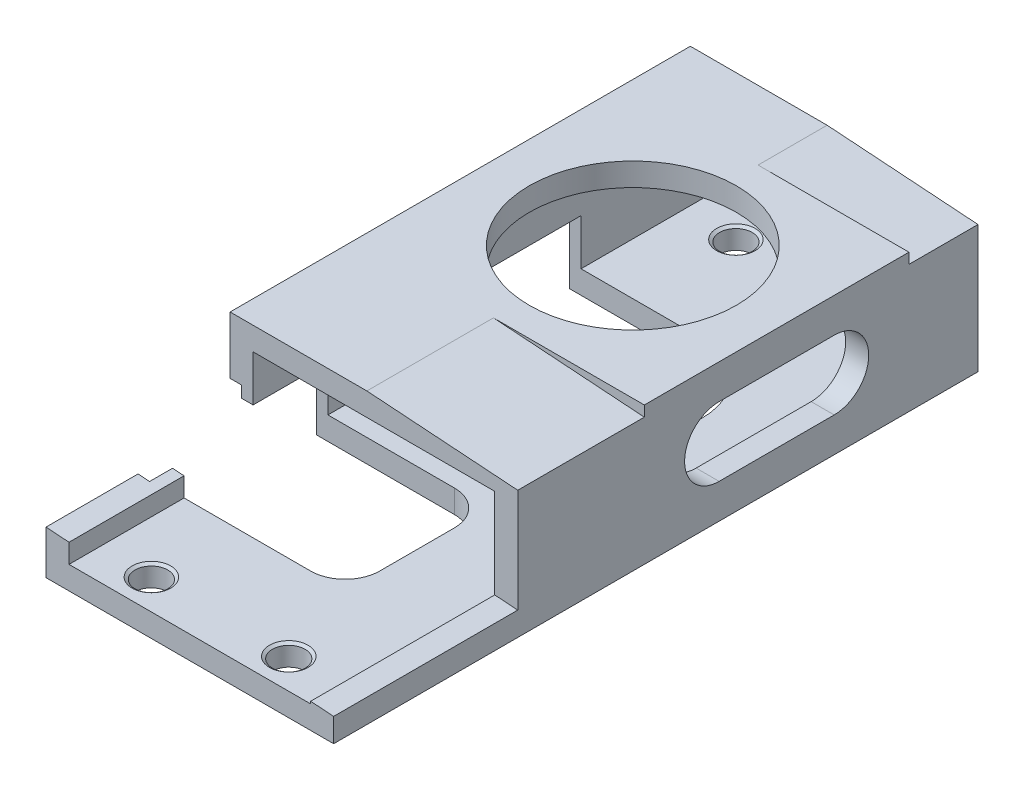
from build123d import *

# Parameters (mm, degrees)
SKETCH_1_W                   = 25
SKETCH_1_H                   = 12
SKETCH_1_W_2                 = 21
SKETCH_1_H_2                 = 8
EXTRUDE_1_DEPTH              = 56
CUT_EXTRUDE_1_REACH          = 14
SKETCH_2_R                   = 9
HOLE_WIZARD_4_401_AT_2_COUNT = 2
HOLE_WIZARD_4_401_AT_2_PITCH = 50.8
HOLE_WIZARD_4_401_AT_3_COUNT = 2
HOLE_WIZARD_4_401_AT_3_PITCH = 52.184323316
HOLE_WIZARD_4_401_AT_4_COUNT = 2
HOLE_WIZARD_4_401_AT_4_PITCH = 11.94
CUT_EXTRUDE_2_DEPTH          = 6
CUT_EXTRUDE_4_DEPTH          = 1
CUT_EXTRUDE_8_REACH          = 27
CUT_EXTRUDE_9_DEPTH          = 6
CUT_EXTRUDE_START            = -56
CUT_EXTRUDE_10_DEPTH         = 27
SKETCH_15_W                  = 30.69445118
SKETCH_15_H                  = 18.97035636
CUT_EXTRUDE_11_DEPTH         = 9


with BuildPart() as part:
    # Sketch 1 → Extrude 1 (new body)
    with BuildSketch(Plane.XY):
        Rectangle(SKETCH_1_W, SKETCH_1_H)
        Rectangle(SKETCH_1_W_2, SKETCH_1_H_2, mode=Mode.SUBTRACT)
    extrude(amount=EXTRUDE_1_DEPTH)

    # Sketch 2 → Cut-Extrude 1 (cut, up to next)
    with BuildSketch(Plane(origin=(0, 6, 0), x_dir=(1, 0, 0), z_dir=(0, 1, 0)), mode=Mode.PRIVATE) as cut_extrude_1_sk1:
        with Locations((0, -17.5)):
            Circle(SKETCH_2_R)
    cut_extrude_1_tool1 = extrude(cut_extrude_1_sk1.sketch, amount=-CUT_EXTRUDE_1_REACH, mode=Mode.PRIVATE) & part.part
    add(cut_extrude_1_tool1.solids().sort_by_distance((0, 6, 17.5))[0], mode=Mode.SUBTRACT)

    # Sketch 3 → Hole Wizard 4-401 (revolve, cut)
    with BuildSketch(Plane(origin=(5.97, -6, 53.37), x_dir=(0, 0, -1), z_dir=(1, 0, 0))):
        Polygon((0, 0), (0, 2), (1.6764, 2), (1.4224, 1.822147285), (1.4224, 0.177852715), (1.6764, 0), align=None)
    hole_wizard_4_401 = revolve(axis=Axis((5.97, -12.35, 53.37), (0, 1, 0)), mode=Mode.SUBTRACT)

    # Hole Wizard 4-401 at 2: Hole Wizard 4-401 ×2
    with Locations(*[(0, 0, -i * HOLE_WIZARD_4_401_AT_2_PITCH) for i in range(1, HOLE_WIZARD_4_401_AT_2_COUNT)]):
        add(hole_wizard_4_401, mode=Mode.SUBTRACT)

    # Hole Wizard 4-401 at 3: Hole Wizard 4-401 ×2
    with Locations(*[Vector(-0.228804347, 0, -0.973472429) * (i * HOLE_WIZARD_4_401_AT_3_PITCH) for i in range(1, HOLE_WIZARD_4_401_AT_3_COUNT)]):
        add(hole_wizard_4_401, mode=Mode.SUBTRACT)

    # Hole Wizard 4-401 at 4: Hole Wizard 4-401 ×2
    with Locations(*[(-i * HOLE_WIZARD_4_401_AT_4_PITCH, 0, 0) for i in range(1, HOLE_WIZARD_4_401_AT_4_COUNT)]):
        add(hole_wizard_4_401, mode=Mode.SUBTRACT)

    # Sketch 5 → Cut-Extrude 2 (cut)
    with BuildSketch(Plane.XZ.offset(6)):
        with BuildLine():
            Line((-12.5, 11.5), (0, 11.5))
            ThreePointArc((0, 11.5), (6, 17.5), (0, 23.5))
            Line((0, 23.5), (-12.5, 23.5))
            Line((-12.5, 23.5), (-12.5, 11.5))
        make_face()
        with BuildLine():
            Line((-12.5, 46), (0.5, 46))
            ThreePointArc((0.5, 46), (2.621320344, 45.121320344), (3.5, 43))
            Line((3.5, 43), (3.5, 36.5))
            ThreePointArc((3.5, 36.5), (2.621320344, 34.378679656), (0.5, 33.5))
            Line((0.5, 33.5), (-12.5, 33.5))
            Line((-12.5, 33.5), (-12.5, 46))
        make_face()
    extrude(amount=-CUT_EXTRUDE_2_DEPTH, mode=Mode.SUBTRACT)

    # Sketch 8 → Cut-Extrude 4 (cut)
    with BuildSketch(Plane.ZY.offset(12.5)):
        with BuildLine():
            Line((9.5, -6), (9.5, -2))
            ThreePointArc((9.5, -2), (10.378679656, 0.121320344), (12.5, 1))
            Line((12.5, 1), (45, 1))
            ThreePointArc((45, 1), (47.121320344, 0.121320344), (48, -2))
            Line((48, -2), (48, -6))
            Line((48, -6), (9.5, -6))
        make_face()
    extrude(amount=-CUT_EXTRUDE_4_DEPTH, mode=Mode.SUBTRACT)

    # Sketch 13 → Cut-Extrude 8 (cut, up to next)
    with BuildSketch(Plane(origin=(12.5, 0, 0), x_dir=(0, 0, -1), z_dir=(1, 0, 0)), mode=Mode.PRIVATE) as cut_extrude_8_sk1:
        with BuildLine():
            Line((-22.5, 3), (-12.5, 3))
            ThreePointArc((-12.5, 3), (-9.5, 0), (-12.5, -3))
            Line((-12.5, -3), (-22.5, -3))
            ThreePointArc((-22.5, -3), (-25.5, 0), (-22.5, 3))
        make_face()
    cut_extrude_8_tool1 = extrude(cut_extrude_8_sk1.sketch, amount=-CUT_EXTRUDE_8_REACH, mode=Mode.PRIVATE) & part.part
    add(cut_extrude_8_tool1.solids().sort_by_distance((12.5, 0, 17.5))[0], mode=Mode.SUBTRACT)

    # Sketch 14 → Cut-Extrude 9 (cut)
    with BuildSketch(Plane(origin=(0, 0, 0), x_dir=(-1, 0, 0), z_dir=(0, 0, -1))):
        Polygon((-12.5, 6), (-12.5, 5.083085997), (0.612481145, 6), align=None)
    extrude(amount=-CUT_EXTRUDE_9_DEPTH, mode=Mode.SUBTRACT)

    # Sketch 14_3 → Cut-Extrude 10 (cut)
    with BuildSketch(Plane(origin=(0, 0, 0), x_dir=(-1, 0, 0), z_dir=(0, 0, -1)).offset(CUT_EXTRUDE_START)):
        Polygon((-12.5, 6), (-12.5, 5.083085997), (0.612481145, 6), align=None)
    extrude(amount=CUT_EXTRUDE_10_DEPTH, mode=Mode.SUBTRACT)

    # Sketch 15 → Cut-Extrude 11 (cut)
    with BuildSketch(Plane(origin=(0.414538991, 5.928183756, 0), x_dir=(0.99756405, -0.069756474, 0), z_dir=(0.069756474, 0.99756405, 0))):
        with Locations((-0.241417032, -49.48517818)):
            Rectangle(SKETCH_15_W, SKETCH_15_H)
    extrude(amount=-CUT_EXTRUDE_11_DEPTH, mode=Mode.SUBTRACT)


solid = part.part
